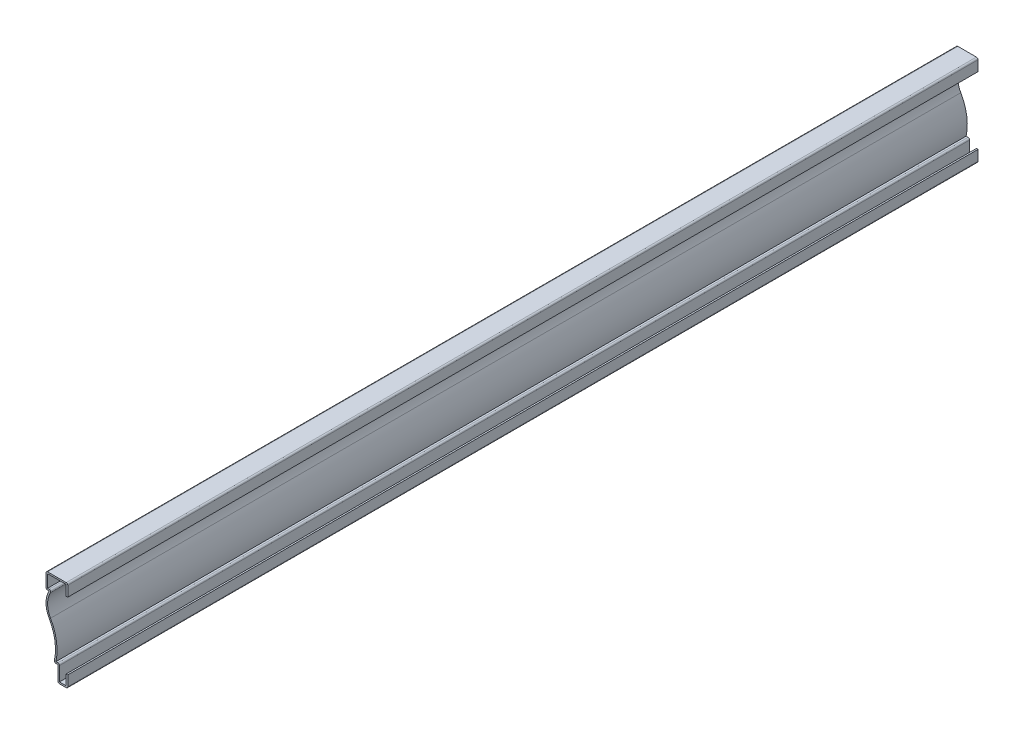
from build123d import *

# Parameters (mm, degrees)
EXTRUDE_THIN1_DEPTH = 730.25
FILLET1_R           = 1.27


with BuildPart() as part:
    # Sketch1 → Extrude-Thin1 (new body)
    with BuildSketch(Plane.XY):
        with BuildLine():
            Line((0, 9.525), (0, 0))
            Line((0, 0), (-7.9375, 0))
            Line((-7.9375, 0), (-7.9375, 12.7))
            Line((-7.9375, 12.7), (-11.1125, 12.7))
            ThreePointArc((-11.1125, 12.7), (-10.20024403, 27.398491684), (-14.930423029, 41.344934793))
            ThreePointArc((-14.930423029, 41.344934793), (-17.4625, 50.834967397), (-14.930423029, 60.325))
            Line((-14.930423029, 60.325), (-17.4625, 60.325))
            Line((-17.4625, 60.325), (-17.4625, 73.025))
            Line((-17.4625, 73.025), (0, 73.025))
            Line((0, 73.025), (0, 63.5))
            Line((0, 63.5), (-1.27, 63.5))
            Line((-1.27, 63.5), (-1.27, 71.755))
            Line((-1.27, 71.755), (-16.1925, 71.755))
            Line((-16.1925, 71.755), (-16.1925, 61.595))
            Line((-16.1925, 61.595), (-12.567008058, 61.595))
            ThreePointArc((-12.567008058, 61.595), (-16.155810371, 51.976605288), (-13.82922816, 41.977603633))
            ThreePointArc((-13.82922816, 41.977603633), (-9.057980708, 28.376690897), (-9.501700135, 13.97))
            Line((-9.501700135, 13.97), (-6.6675, 13.97))
            Line((-6.6675, 13.97), (-6.6675, 1.27))
            Line((-6.6675, 1.27), (-1.27, 1.27))
            Line((-1.27, 1.27), (-1.27, 9.525))
            Line((-1.27, 9.525), (0, 9.525))
        make_face()
    extrude(amount=-EXTRUDE_THIN1_DEPTH)

    # Fillet1
    fillet1_edges = [part.edges().sort_by_distance(p)[0] for p in [
        (-12.567008058, 61.595, -365.125),
        (-6.6675, 13.97, -365.125),
        (0, 0, -365.125),
        (-7.9375, 0, -365.125),
        (-11.1125, 12.7, -365.125),
        (-17.4625, 60.325, -365.125),
        (-17.4625, 73.025, -365.125),
        (0, 73.025, -365.125),
    ]]
    fillet(fillet1_edges, radius=FILLET1_R)


solid = part.part
